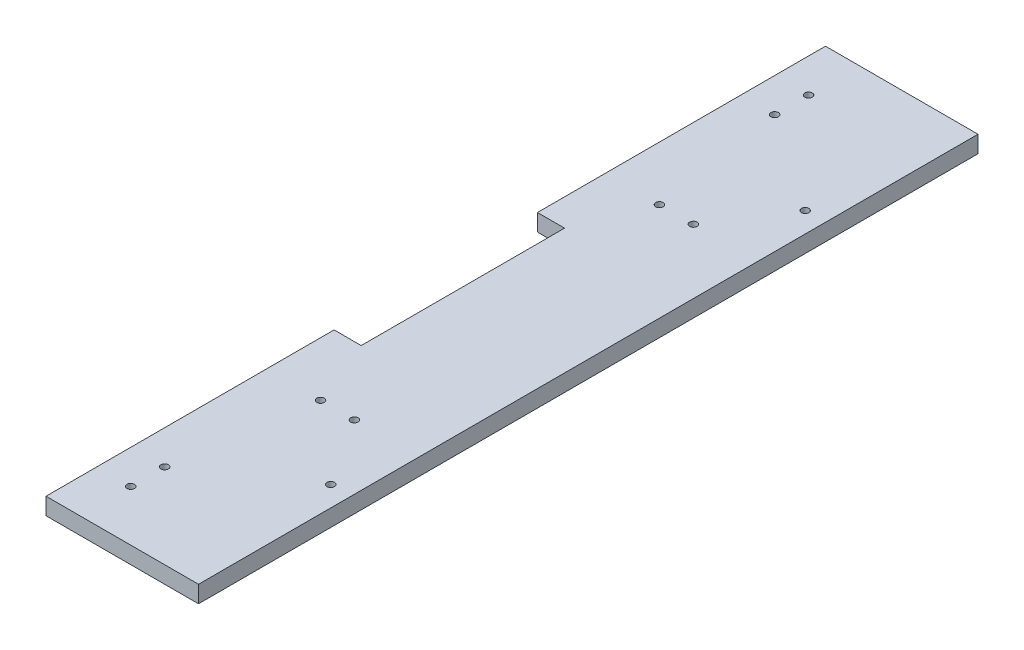
from build123d import *

# Parameters (mm, degrees)
SKETCH1_W                      = 5
SKETCH1_H                      = 110
BOSS_EXTRUDE1_DEPTH            = 120
BOSS_EXTRUDE1_DEPTH_BACK       = 110
BOSS_EXTRUDE1_2_DEPTH          = 120
BOSS_EXTRUDE1_2_DEPTH_BACK     = 110
SKETCH2_W                      = 5
SKETCH2_H                      = 37
BOSS_EXTRUDE2_DEPTH            = 50
SKETCH3_W                      = 220
SKETCH3_H                      = 5
BOSS_EXTRUDE3_DEPTH            = 50
SKETCH4_W                      = 230
SKETCH4_H                      = 73
BOSS_EXTRUDE6_DEPTH            = 5
CUT_EXTRUDE3_DEPTH             = 231
SKETCH5_W                      = 348
SKETCH5_H                      = 227
SKETCH5_W_2                    = 328
SKETCH5_H_2                    = 207
BOSS_EXTRUDE7_DEPTH            = 5
BOSS_EXTRUDE8_DEPTH            = 59
FILLET5_R                      = 15
BOSS_EXTRUDE9_DEPTH            = 5
BOSS_EXTRUDE10_DEPTH           = 5
FILLET6_R                      = 3
CUT_EXTRUDE4_DEPTH             = 165.048773235
SKETCH15_W                     = 45
SKETCH15_H                     = 32
CUT_EXTRUDE5_DEPTH             = 1
CUT_EXTRUDE5_DEPTH_BACK        = 231
SKETCH16_R                     = 1.1
HOLES_FOR_PART_1_DEPTH         = 6
SKETCH17_R                     = 1.1
HOLES_FOR_FORWARD_PART_4_DEPTH = 6
SKETCH18_R                     = 1.1
HOLES_FOR_FORWARD_PART_2_DEPTH = 6
SKETCH19_W                     = 16
SKETCH19_H                     = 60
CUT_EXTRUDE6_DEPTH             = 6


with BuildPart() as part:
    # Sketch1 → Boss-Extrude1 (new body, two sides)
    with BuildSketch(Plane(origin=(0, 0, 0), x_dir=(0, 0, -1), z_dir=(1, 0, 0))) as boss_extrude1_sk:
        with Locations((-112.5, 55)):
            Rectangle(SKETCH1_W, SKETCH1_H)
    extrude(amount=BOSS_EXTRUDE1_DEPTH)
    extrude(boss_extrude1_sk.sketch, amount=-BOSS_EXTRUDE1_DEPTH_BACK)



with BuildPart() as body_2:
    # Sketch1 → Boss-Extrude1 2 (new body, two sides)
    with BuildSketch(Plane(origin=(0, 0, 0), x_dir=(0, 0, -1), z_dir=(1, 0, 0))) as boss_extrude1_2_sk:
        with Locations((112.5, 55)):
            Rectangle(SKETCH1_W, SKETCH1_H)
    extrude(amount=BOSS_EXTRUDE1_2_DEPTH)
    extrude(boss_extrude1_2_sk.sketch, amount=-BOSS_EXTRUDE1_2_DEPTH_BACK)


with BuildPart() as part_1:
    add(part.part)

    add(body_2.part)  # Boss-Extrude2 merges body 2
    # Sketch2 → Boss-Extrude2 (add)
    with BuildSketch(Plane.ZY.offset(110)):
        with Locations((-112.5, 18.5)):
            Rectangle(SKETCH2_W, SKETCH2_H)
        with Locations((112.5, 18.5)):
            Rectangle(SKETCH2_W, SKETCH2_H)
    extrude(amount=BOSS_EXTRUDE2_DEPTH)

    # Sketch3 → Boss-Extrude3 (add)
    with BuildSketch(Plane.ZY.offset(160)):
        with Locations((0, 34.5)):
            Rectangle(SKETCH3_W, SKETCH3_H)
    extrude(amount=-BOSS_EXTRUDE3_DEPTH)

    # Sketch4 → Boss-Extrude6 (add)
    with BuildSketch(Plane.ZY.offset(110)):
        with Locations((0, 73.5)):
            Rectangle(SKETCH4_W, SKETCH4_H)
    extrude(amount=BOSS_EXTRUDE6_DEPTH)

    # Sketch9 → Cut-Extrude3 (cut, through all)
    with BuildSketch(Plane.XY.offset(115)):
        Polygon((120, 110), (116.464466094, 106.464466094), (120, 102.928932188), align=None)
    extrude(amount=-CUT_EXTRUDE3_DEPTH, mode=Mode.SUBTRACT)

    # Sketch10 → Boss-Extrude8 (add)
    with BuildSketch(Plane.XY.offset(115)):
        Polygon((120, 110), (111.464466094, 110), (111.464466094, 0), (120, 0), (120, 102.928932188), (116.464466094, 106.464466094), align=None)
    boss_extrude8 = extrude(amount=BOSS_EXTRUDE8_DEPTH)

    # Mirror3: Boss-Extrude8 across plane
    add(boss_extrude8.mirror(Plane.XY))

    # Fillet5
    fillet5_edges = [part_1.edges().sort_by_distance(p)[0] for p in [
        (111.464466094, 55, 115),
        (111.464466094, 55, -115),
    ]]
    fillet(fillet5_edges, radius=FILLET5_R)

    # Fillet6
    fillet6_edges = [part_1.edges().sort_by_distance(p)[0] for p in [
        (111.464466094, 55, 174),
        (111.464466094, 55, -174),
    ]]
    fillet(fillet6_edges, radius=FILLET6_R)


with BuildPart() as body_2_2:
    # Sketch5 → Boss-Extrude7 (new body)
    with BuildSketch(Plane(origin=(115, 115, 0), x_dir=(0, 0, 1), z_dir=(-0.707106781, -0.707106781, 0))):
        with Locations((0, -120.571067812)):
            Rectangle(SKETCH5_W, SKETCH5_H)
        with Locations((0, -120.571067812)):
            Rectangle(SKETCH5_W_2, SKETCH5_H_2, mode=Mode.SUBTRACT)
    extrude(amount=BOSS_EXTRUDE7_DEPTH)


with BuildPart() as body_3:
    # Sketch12 → Boss-Extrude9 (new body)
    with BuildSketch(Plane.XY.offset(174)):
        Polygon((120, 0), (222.928932188, 0), (120, 102.928932188), align=None)
    extrude(amount=-BOSS_EXTRUDE9_DEPTH)


with BuildPart() as body_4:
    # Sketch13 → Boss-Extrude10 (new body)
    with BuildSketch(Plane(origin=(0, 0, -174), x_dir=(-1, 0, 0), z_dir=(0, 0, -1))):
        Polygon((-120, 102.928932188), (-120, 0), (-222.928932188, 0), align=None)
    extrude(amount=-BOSS_EXTRUDE10_DEPTH)


with BuildPart() as cut_extrude4_tool:
    # Sketch14 → Cut-Extrude4 (new body, through all)
    with BuildSketch(Plane(origin=(0, 110, 0), x_dir=(1, 0, 0), z_dir=(0, 1, 0))):
        Polygon((-115, 115), (-115, -115), (-167.30995795, -115), (-167.30995795, -200.602059027), (289.684331767, -200.602059027), (289.684331767, -115), (289.684331767, 105), (289.684331767, 193.761157723), (-167.30995795, 193.761157723), (-167.30995795, 115), align=None)
    extrude(amount=-CUT_EXTRUDE4_DEPTH)


with BuildPart() as part_2:
    add(part_1.part)

    # Cut-Extrude4: cut by cut_extrude4_tool
    add(cut_extrude4_tool.part, mode=Mode.SUBTRACT)

    # Sketch15 → Cut-Extrude5 (cut, two sides)
    with BuildSketch(Plane.XY.offset(115)) as cut_extrude5_sk:
        with Locations((-137.5, 16)):
            Rectangle(SKETCH15_W, SKETCH15_H)
    extrude(amount=CUT_EXTRUDE5_DEPTH, mode=Mode.SUBTRACT)
    extrude(cut_extrude5_sk.sketch, amount=-CUT_EXTRUDE5_DEPTH_BACK, mode=Mode.SUBTRACT)

    # Sketch16 → Holes for part 1 (cut, through all)
    with BuildSketch(Plane(origin=(0, 37, 0), x_dir=(1, 0, 0), z_dir=(0, 1, 0))):
        with Locations((-150, -100)):
            Circle(SKETCH16_R)
        with Locations((-150, -90)):
            Circle(SKETCH16_R)
        with Locations((-150, 90)):
            Circle(SKETCH16_R)
        with Locations((-150, 100)):
            Circle(SKETCH16_R)
    extrude(amount=-HOLES_FOR_PART_1_DEPTH, mode=Mode.SUBTRACT)

    # Sketch17 → Holes for forward part 4 (cut, through all)
    with BuildSketch(Plane(origin=(0, 37, 0), x_dir=(1, 0, 0), z_dir=(0, 1, 0))):
        with Locations((-121, 70)):
            Circle(SKETCH17_R)
        with Locations((-121, -70)):
            Circle(SKETCH17_R)
    extrude(amount=-HOLES_FOR_FORWARD_PART_4_DEPTH, mode=Mode.SUBTRACT)

    # Sketch18 → Holes for forward part 2 (cut, through all)
    with BuildSketch(Plane(origin=(0, 37, 0), x_dir=(1, 0, 0), z_dir=(0, 1, 0))):
        with Locations((-134, 50)):
            Circle(SKETCH18_R)
        with Locations((-144, 50)):
            Circle(SKETCH18_R)
        with Locations((-144, -50)):
            Circle(SKETCH18_R)
        with Locations((-134, -50)):
            Circle(SKETCH18_R)
    extrude(amount=-HOLES_FOR_FORWARD_PART_2_DEPTH, mode=Mode.SUBTRACT)

    # Sketch19 → Cut-Extrude6 (cut, through all)
    with BuildSketch(Plane(origin=(0, 37, 0), x_dir=(1, 0, 0), z_dir=(0, 1, 0))):
        with Locations((-160, 0)):
            Rectangle(SKETCH19_W, SKETCH19_H)
    extrude(amount=-CUT_EXTRUDE6_DEPTH, mode=Mode.SUBTRACT)


with BuildPart() as body_2_2_1:
    add(body_2_2.part)

    # Cut-Extrude4: cut by cut_extrude4_tool
    add(cut_extrude4_tool.part, mode=Mode.SUBTRACT)


with BuildPart() as body_3_1:
    add(body_3.part)

    # Cut-Extrude4: cut by cut_extrude4_tool
    add(cut_extrude4_tool.part, mode=Mode.SUBTRACT)


with BuildPart() as body_4_1:
    add(body_4.part)

    # Cut-Extrude4: cut by cut_extrude4_tool
    add(cut_extrude4_tool.part, mode=Mode.SUBTRACT)


solid = part_2.part
